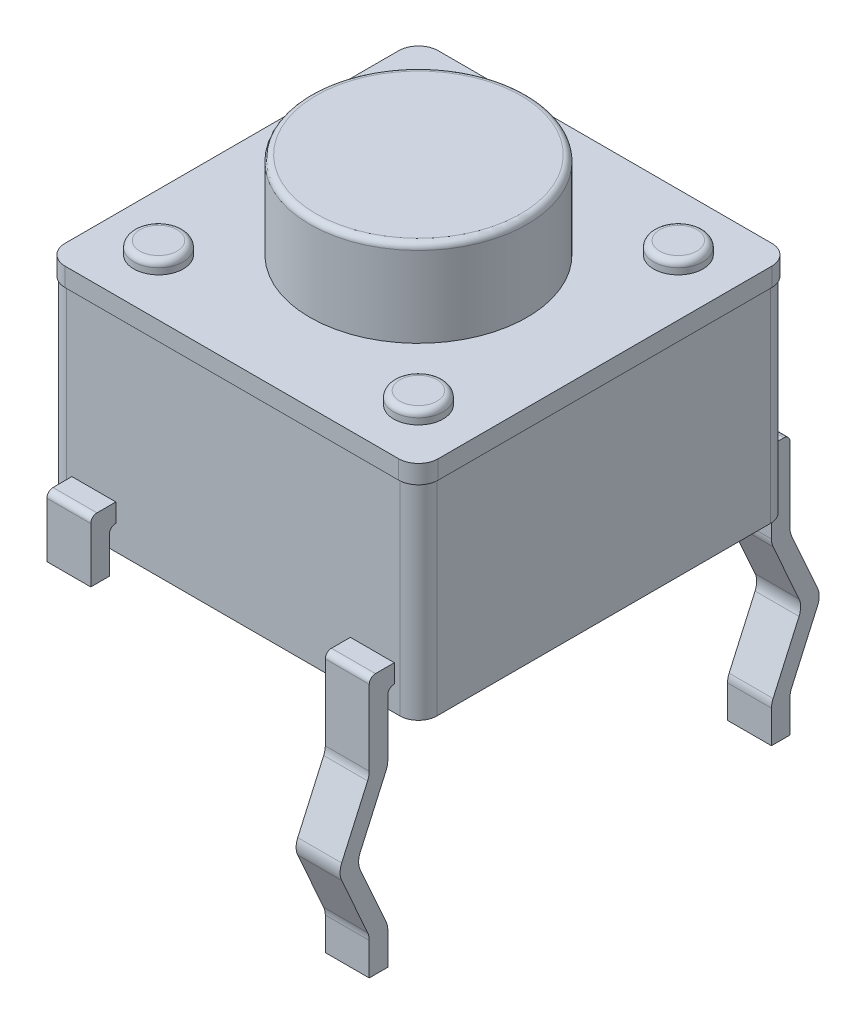
from build123d import *

# Parameters (mm, degrees)
RESSALTO_EXTRUS_O1_DEPTH = 3.61
ESBO_O2_R                = 1.755
RESSALTO_EXTRUS_O2_DEPTH = 1.4
FILETE1_R                = 0.1
ESBO_O3_R                = 0.4
RESSALTO_EXTRUS_O3_DEPTH = 0.2
FILETE2_R                = 0.1
RESSALTO_EXTRUS_O4_DEPTH = 0.3
RESSALTO_EXTRUS_O5_DEPTH = 0.355
ESPELHAR2_COPY_1_DEPTH   = 0.355
CUT_EXTRUDE1_START       = -3.222
SKETCH1_R                = 1.13730051
CUT_EXTRUDE1_DEPTH       = 3.222


with BuildPart() as part:
    # Esboço1 → Ressalto-extrusão1 (new body)
    with BuildSketch(Plane(origin=(0, 0, 0), x_dir=(1, 0, 0), z_dir=(0, 1, 0))):
        with BuildLine():
            Line((-2.695, 2.995), (2.695, 2.995))
            ThreePointArc((2.695, 2.995), (2.907132034, 2.907132034), (2.995, 2.695))
            Line((2.995, 2.695), (2.995, -2.695))
            ThreePointArc((2.995, -2.695), (2.907132034, -2.907132034), (2.695, -2.995))
            Line((2.695, -2.995), (-2.695, -2.995))
            ThreePointArc((-2.695, -2.995), (-2.907132034, -2.907132034), (-2.995, -2.695))
            Line((-2.995, -2.695), (-2.995, 2.695))
            ThreePointArc((-2.995, 2.695), (-2.907132034, 2.907132034), (-2.695, 2.995))
        make_face()
    extrude(amount=RESSALTO_EXTRUS_O1_DEPTH)



with BuildPart() as body_2:
    # Esboço2 → Ressalto-extrusão2 (new body)
    with BuildSketch(Plane(origin=(0, 3.61, 0), x_dir=(1, 0, 0), z_dir=(0, 1, 0))):
        with Locations(Location((0, 0, 0), (0, 0, 270))):
            Circle(ESBO_O2_R)
    extrude(amount=RESSALTO_EXTRUS_O2_DEPTH)

    # Filete1
    filete1_edges = [body_2.edges().sort_by_distance(p)[0] for p in [
        (0, 5.01, -1.755),
    ]]
    fillet(filete1_edges, radius=FILETE1_R)


with BuildPart() as part_1:
    add(part.part)

    add(body_2.part)  # Ressalto-extrusão3 merges body 2
    # Esboço3 → Ressalto-extrusão3 (add)
    with BuildSketch(Plane(origin=(0, 3.61, 0), x_dir=(1, 0, 0), z_dir=(0, 1, 0))):
        with Locations(Location((-2.1, 2.1, 0), (0, 0, 270))):
            Circle(ESBO_O3_R)
        with Locations(Location((2.1, 2.1, 0), (0, 0, 90))):
            Circle(ESBO_O3_R)
        with Locations(Location((2.1, -2.1, 0), (0, 0, 270))):
            Circle(ESBO_O3_R)
        with Locations(Location((-2.1, -2.1, 0), (0, 0, 90))):
            Circle(ESBO_O3_R)
    extrude(amount=RESSALTO_EXTRUS_O3_DEPTH)

    # Filete2
    filete2_edges = [part_1.edges().sort_by_distance(p)[0] for p in [
        (-2.1, 3.81, -2.5),
        (2.1, 3.81, -1.7),
        (2.1, 3.81, 1.7),
        (-2.1, 3.81, 2.5),
    ]]
    fillet(filete2_edges, radius=FILETE2_R)

    # Esboço4 → Ressalto-extrusão4 (add)
    with BuildSketch(Plane(origin=(0, 3.61, 0), x_dir=(1, 0, 0), z_dir=(0, 1, 0))):
        with BuildLine():
            Line((-2.695, -3.015), (2.695, -3.015))
            ThreePointArc((2.695, -3.015), (2.92127417, -2.92127417), (3.015, -2.695))
            Line((3.015, -2.695), (3.015, 2.695))
            ThreePointArc((3.015, 2.695), (2.92127417, 2.92127417), (2.695, 3.015))
            Line((2.695, 3.015), (-2.695, 3.015))
            ThreePointArc((-2.695, 3.015), (-2.92127417, 2.92127417), (-3.015, 2.695))
            Line((-3.015, 2.695), (-3.015, -2.695))
            ThreePointArc((-3.015, -2.695), (-2.92127417, -2.92127417), (-2.695, -3.015))
        make_face()
    extrude(amount=-RESSALTO_EXTRUS_O4_DEPTH)

    # Esboço5 → Ressalto-extrusão5 (add, symmetric)
    with BuildSketch(Plane(origin=(2.25, 0, 0), x_dir=(0, 0, -1), z_dir=(1, 0, 0))):
        with BuildLine():
            Line((2.995, 0.4), (3, 0.4))
            ThreePointArc((3, 0.4), (3.070710678, 0.370710678), (3.1, 0.3))
            Line((3.1, 0.3), (3.1, -0.616076091))
            ThreePointArc((3.1, -0.616076091), (3.106586972, -0.67859645), (3.126058635, -0.738371343))
            Line((3.126058635, -0.738371343), (3.545403905, -1.677704748))
            ThreePointArc((3.545403905, -1.677704748), (3.571462541, -1.8), (3.545403905, -1.922295252))
            Line((3.545403905, -1.922295252), (3.126058635, -2.861628657))
            ThreePointArc((3.126058635, -2.861628657), (3.106586972, -2.92140355), (3.1, -2.983923909))
            Line((3.1, -2.983923909), (3.1, -3.51))
            Line((3.1, -3.51), (3.4, -3.51))
            Line((3.4, -3.51), (3.4, -2.983923909))
            ThreePointArc((3.4, -2.983923909), (3.406586972, -2.92140355), (3.426058635, -2.861628657))
            Line((3.426058635, -2.861628657), (3.845403905, -1.922295252))
            ThreePointArc((3.845403905, -1.922295252), (3.871462541, -1.8), (3.845403905, -1.677704748))
            Line((3.845403905, -1.677704748), (3.426058635, -0.738371343))
            ThreePointArc((3.426058635, -0.738371343), (3.406586972, -0.67859645), (3.4, -0.616076091))
            Line((3.4, -0.616076091), (3.4, 0.6))
            ThreePointArc((3.4, 0.6), (3.370710678, 0.670710678), (3.3, 0.7))
            Line((3.3, 0.7), (2.995, 0.7))
            Line((2.995, 0.7), (2.995, 0.4))
        make_face()
    ressalto_extrus_o5 = extrude(amount=RESSALTO_EXTRUS_O5_DEPTH, both=True)

    # Espelhar1: Ressalto-extrusão5 across plane
    add(ressalto_extrus_o5.mirror(Plane(origin=(0, 0, 0), x_dir=(0, 0, 1), z_dir=(1, 0, 0))))

    # Espelhar2: Ressalto-extrusão5 across plane
    add(ressalto_extrus_o5.mirror(Plane.XY))

    # Espelhar2 copy 1 sketch → Espelhar2 copy 1 (add, symmetric)
    with BuildSketch(Plane.ZY.offset(2.25)):
        with BuildLine():
            Line((2.995, 0.4), (3, 0.4))
            ThreePointArc((3, 0.4), (3.070710678, 0.370710678), (3.1, 0.3))
            Line((3.1, 0.3), (3.1, -0.616076091))
            ThreePointArc((3.1, -0.616076091), (3.106586972, -0.67859645), (3.126058635, -0.738371343))
            Line((3.126058635, -0.738371343), (3.545403905, -1.677704748))
            ThreePointArc((3.545403905, -1.677704748), (3.571462541, -1.8), (3.545403905, -1.922295252))
            Line((3.545403905, -1.922295252), (3.126058635, -2.861628657))
            ThreePointArc((3.126058635, -2.861628657), (3.106586972, -2.92140355), (3.1, -2.983923909))
            Line((3.1, -2.983923909), (3.1, -3.51))
            Line((3.1, -3.51), (3.4, -3.51))
            Line((3.4, -3.51), (3.4, -2.983923909))
            ThreePointArc((3.4, -2.983923909), (3.406586972, -2.92140355), (3.426058635, -2.861628657))
            Line((3.426058635, -2.861628657), (3.845403905, -1.922295252))
            ThreePointArc((3.845403905, -1.922295252), (3.871462541, -1.8), (3.845403905, -1.677704748))
            Line((3.845403905, -1.677704748), (3.426058635, -0.738371343))
            ThreePointArc((3.426058635, -0.738371343), (3.406586972, -0.67859645), (3.4, -0.616076091))
            Line((3.4, -0.616076091), (3.4, 0.6))
            ThreePointArc((3.4, 0.6), (3.370710678, 0.670710678), (3.3, 0.7))
            Line((3.3, 0.7), (2.995, 0.7))
            Line((2.995, 0.7), (2.995, 0.4))
        make_face()
    extrude(amount=ESPELHAR2_COPY_1_DEPTH, both=True)

    # Sketch1 → Cut-Extrude1 (cut)
    with BuildSketch(Plane.XZ.offset(3.51).offset(CUT_EXTRUDE1_START)):
        with Locations((-2.208312021, 3.262441574)):
            Circle(SKETCH1_R)
    extrude(amount=CUT_EXTRUDE1_DEPTH, mode=Mode.SUBTRACT)


solid = part_1.part
